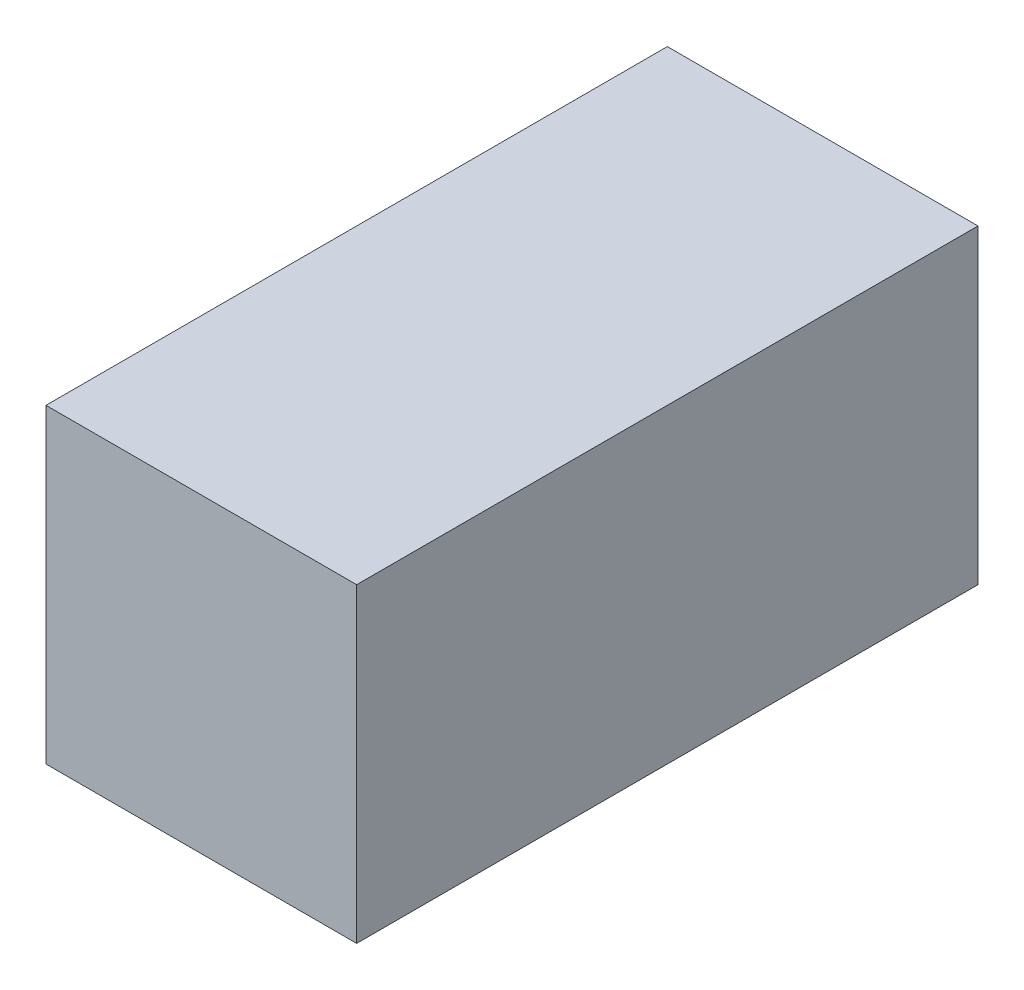
from build123d import *

# Parameters (mm, degrees)
SKETCH1_W           = 5
SKETCH1_H           = 5
BOSS_EXTRUDE1_DEPTH = 10


with BuildPart() as part:
    # Sketch1 → Boss-Extrude1 (new body)
    with BuildSketch(Plane.XY):
        Rectangle(SKETCH1_W, SKETCH1_H)
    extrude(amount=BOSS_EXTRUDE1_DEPTH)


solid = part.part
